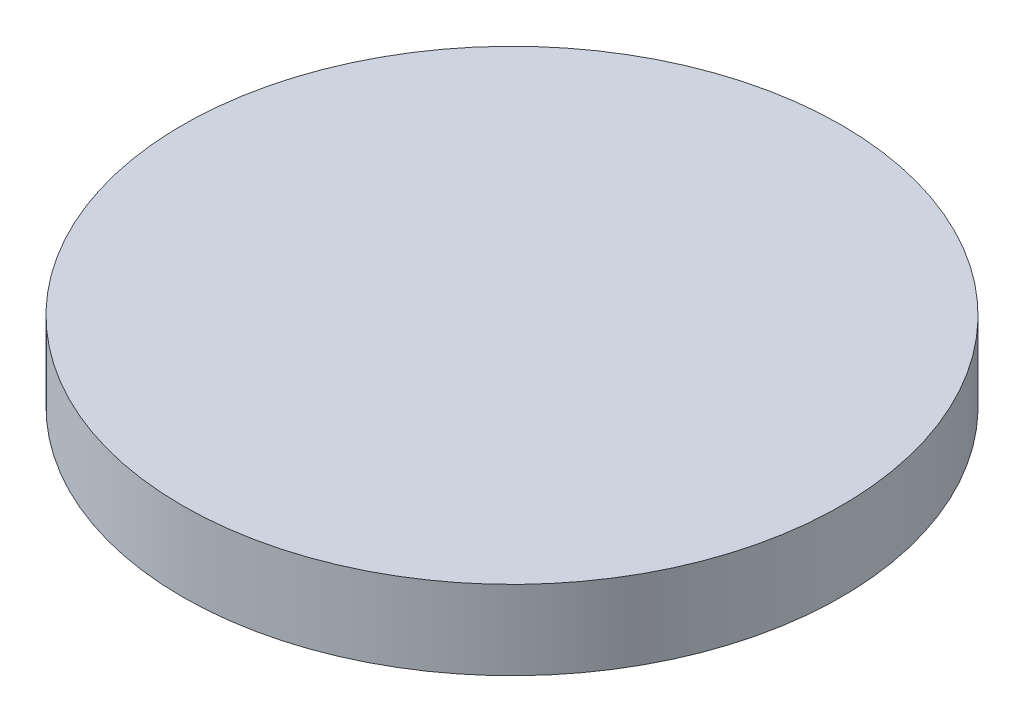
from build123d import *

# Parameters (mm, degrees)
SKETCH1_R           = 63.5
BOSS_EXTRUDE1_DEPTH = 15.24


with BuildPart() as part:
    # Sketch1 → Boss-Extrude1 (new body)
    with BuildSketch(Plane(origin=(0, 0, 0), x_dir=(1, 0, 0), z_dir=(0, 1, 0))):
        Circle(SKETCH1_R)
    extrude(amount=BOSS_EXTRUDE1_DEPTH)


solid = part.part
